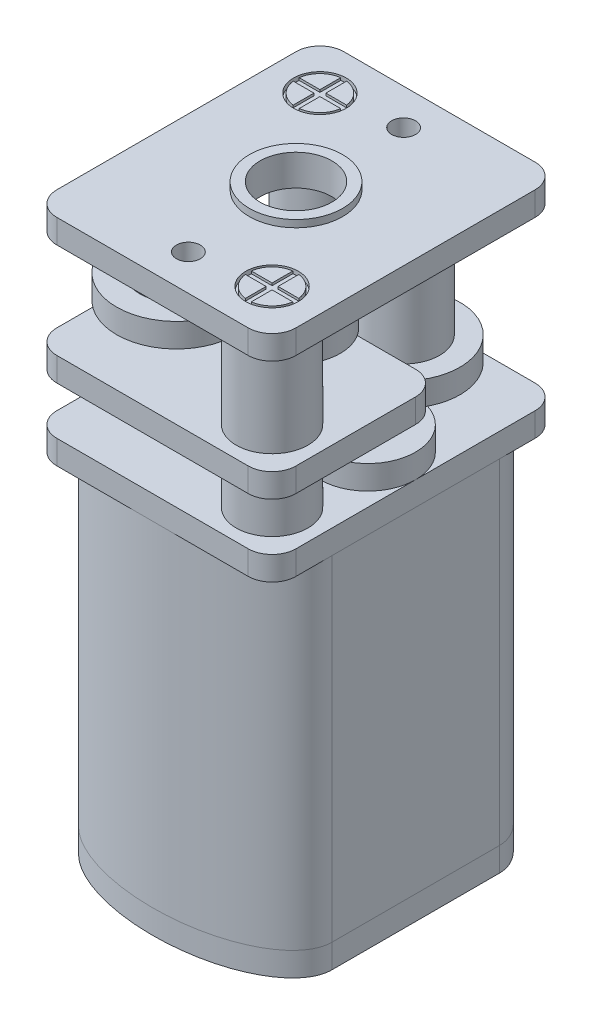
from build123d import *

# Parameters (mm, degrees)
SALIENTE_EXTRUIR1_DEPTH       = 1
CROQUIS2_R                    = 2.5
SALIENTE_EXTRUIR2_DEPTH       = 1
CROQUIS3_R                    = 1
CORTAR_EXTRUIR1_DEPTH         = 0.5
CROQUIS4_W                    = 1.5
CROQUIS4_H                    = 0.3
SALIENTE_EXTRUIR3_DEPTH       = 1.5
CROQUIS5_R                    = 0.5
CORTAR_EXTRUIR2_DEPTH         = 0.3
CROQUIS6_R                    = 0.5
CORTAR_EXTRUIR3_DEPTH         = 0.3
SALIENTE_EXTRUIR4_DEPTH       = 14
CROQUIS8_W                    = 10
CROQUIS8_H                    = 12
SALIENTE_EXTRUIR5_DEPTH       = 1
CROQUIS23_R                   = 1
SALIENTE_EXTRUIR13_DEPTH      = 1
CROQUIS25_R                   = 2
SALIENTE_EXTRUIR18_DEPTH      = 1
CROQUIS26_R                   = 1
SALIENTE_EXTRUIR19_DEPTH      = 1
CROQUIS27_R                   = 2.354101966
SALIENTE_EXTRUIR21_DEPTH      = 1
CROQUIS29_R                   = 1.5
SALIENTE_EXTRUIR22_DEPTH      = 3
REDONDEO1_R                   = 1
REDONDEO2_R                   = 1
REDONDEO3_R                   = 1
REDONDEO4_R                   = 1
CROQUIS9_R                    = 1.5
SALIENTE_EXTRUIR6_DEPTH       = 2
CROQUIS10_W                   = 10
CROQUIS10_H                   = 12
SALIENTE_EXTRUIR7_DEPTH       = 1
CROQUIS11_R                   = 1.5
SALIENTE_EXTRUIR8_DEPTH       = 4
CROQUIS12_W                   = 5
CROQUIS12_H                   = 5
CORTAR_EXTRUIR4_DEPTH         = 1
CROQUIS30_R                   = 1.854101966
SALIENTE_EXTRUIR24_DEPTH      = 1
CROQUIS31_R                   = 1
SALIENTE_EXTRUIR26_DEPTH      = 1
CROQUIS32_R                   = 2.5
SALIENTE_EXTRUIR27_DEPTH      = 1
CROQUIS33_R                   = 1.535533906
SALIENTE_EXTRUIR28_DEPTH      = 2
CROQUIS34_R                   = 0.2
SALIENTE_EXTRUIR29_DEPTH      = 2
SALIENTE_EXTRUIR29_DEPTH_BACK = 5
CROQUIS35_R                   = 0.2
SALIENTE_EXTRUIR30_DEPTH      = 4
CROQUIS36_R                   = 0.2
SALIENTE_EXTRUIR31_DEPTH      = 2
REDONDEO5_R                   = 1
REDONDEO6_R                   = 1
REDONDEO7_R                   = 1
REDONDEO8_R                   = 1
REDONDEO9_R                   = 1
CROQUIS13_W                   = 10
CROQUIS13_H                   = 12
SALIENTE_EXTRUIR9_DEPTH       = 1
CROQUIS14_R                   = 1.95
CROQUIS14_R_2                 = 1.5
SALIENTE_EXTRUIR10_DEPTH      = 0.3
CROQUIS15_R                   = 0.5
CORTAR_EXTRUIR5_DEPTH         = 1
CROQUIS16_R                   = 1.1
CORTAR_EXTRUIR6_DEPTH         = 0.2
CROQUIS17_R                   = 1
SALIENTE_EXTRUIR11_DEPTH      = 0.2
CROQUIS18_R                   = 1
SALIENTE_EXTRUIR12_DEPTH      = 0.2
CORTAR_EXTRUIR7_DEPTH         = 0.1
CORTAR_EXTRUIR8_DEPTH         = 0.1
REDONDEO10_R                  = 1
REDONDEO11_R                  = 1
REDONDEO12_R                  = 1
REDONDEO13_R                  = 1
REDONDEO14_R                  = 1
CROQUIS22_R                   = 1.5
CORTAR_EXTRUIR9_DEPTH         = 1


with BuildPart() as part:
    # Croquis1 → Saliente-Extruir1 (new body)
    with BuildSketch(Plane(origin=(0, 0, 0), x_dir=(1, 0, 0), z_dir=(0, 1, 0))):
        with BuildLine():
            Line((5, 3.5), (5, -3.5))
            add(Edge.make_bspline(
                [(-5, -3.5), (-5, -6), (0, -6), (5, -6), (5, -3.5)],
                knots=[3.141592654, 3.141592654, 3.141592654, 4.71238898, 4.71238898, 6.283185307, 6.283185307, 6.283185307], degree=2, weights=[1, 0.707106781, 1, 0.707106781, 1]))
            Line((-5, -3.5), (-5, 3.5))
            add(Edge.make_bspline(
                [(5, 3.5), (5, 6), (0, 6), (-5, 6), (-5, 3.5)],
                knots=[3.141592654, 3.141592654, 3.141592654, 4.71238898, 4.71238898, 6.283185307, 6.283185307, 6.283185307], degree=2, weights=[1, 0.707106781, 1, 0.707106781, 1]))
        make_face()
    extrude(amount=SALIENTE_EXTRUIR1_DEPTH)

    # Croquis2 → Saliente-Extruir2 (add)
    with BuildSketch(Plane.XZ):
        Circle(CROQUIS2_R)
    extrude(amount=SALIENTE_EXTRUIR2_DEPTH)

    # Croquis3 → Cortar-Extruir1 (cut)
    with BuildSketch(Plane.XZ.offset(1)):
        Circle(CROQUIS3_R)
    extrude(amount=-CORTAR_EXTRUIR1_DEPTH, mode=Mode.SUBTRACT)

    # Croquis4 → Saliente-Extruir3 (add)
    with BuildSketch(Plane.XZ):
        with Locations((0, 3.65)):
            Rectangle(CROQUIS4_W, CROQUIS4_H)
        with Locations((0, -3.65)):
            Rectangle(CROQUIS4_W, CROQUIS4_H)
    extrude(amount=SALIENTE_EXTRUIR3_DEPTH)

    # Croquis5 → Cortar-Extruir2 (cut)
    with BuildSketch(Plane(origin=(0, 0, -3.8), x_dir=(-1, 0, 0), z_dir=(0, 0, -1))):
        with Locations((0, -0.75)):
            Circle(CROQUIS5_R)
    extrude(amount=-CORTAR_EXTRUIR2_DEPTH, mode=Mode.SUBTRACT)

    # Croquis6 → Cortar-Extruir3 (cut)
    with BuildSketch(Plane.XY.offset(3.8)):
        with Locations((0, -0.75)):
            Circle(CROQUIS6_R)
    extrude(amount=-CORTAR_EXTRUIR3_DEPTH, mode=Mode.SUBTRACT)


with BuildPart() as body_2:
    # Croquis7 → Saliente-Extruir4 (new body)
    with BuildSketch(Plane(origin=(0, 1, 0), x_dir=(1, 0, 0), z_dir=(0, 1, 0))):
        with BuildLine():
            Line((-5, 3.5), (-5, -3.5))
            add(Edge.make_bspline(
                [(-5, -3.5), (-5, -6), (0, -6), (5, -6), (5, -3.5)],
                knots=[0, 0, 0, 1.570796327, 1.570796327, 3.141592654, 3.141592654, 3.141592654], degree=2, weights=[1, 0.707106781, 1, 0.707106781, 1]))
            Line((5, -3.5), (5, 3.5))
            add(Edge.make_bspline(
                [(5, 3.5), (5, 6), (0, 6), (-5, 6), (-5, 3.5)],
                knots=[3.141592654, 3.141592654, 3.141592654, 4.71238898, 4.71238898, 6.283185307, 6.283185307, 6.283185307], degree=2, weights=[1, 0.707106781, 1, 0.707106781, 1]))
        make_face()
    extrude(amount=SALIENTE_EXTRUIR4_DEPTH)


with BuildPart() as body_3:
    # Croquis8 → Saliente-Extruir5 (new body)
    with BuildSketch(Plane(origin=(0, 15, 0), x_dir=(1, 0, 0), z_dir=(0, 1, 0))):
        Rectangle(CROQUIS8_W, CROQUIS8_H)
    extrude(amount=SALIENTE_EXTRUIR5_DEPTH)

    # Redondeo1
    redondeo1_edges = [body_3.edges().sort_by_distance(p)[0] for p in [
        (-5, 15.5, -6),
    ]]
    fillet(redondeo1_edges, radius=REDONDEO1_R)

    # Redondeo2
    redondeo2_edges = [body_3.edges().sort_by_distance(p)[0] for p in [
        (5, 15.5, -6),
    ]]
    fillet(redondeo2_edges, radius=REDONDEO2_R)

    # Redondeo3
    redondeo3_edges = [body_3.edges().sort_by_distance(p)[0] for p in [
        (5, 15.5, 6),
    ]]
    fillet(redondeo3_edges, radius=REDONDEO3_R)

    # Redondeo4
    redondeo4_edges = [body_3.edges().sort_by_distance(p)[0] for p in [
        (-5, 15.5, 6),
    ]]
    fillet(redondeo4_edges, radius=REDONDEO4_R)

    # Croquis9 → Saliente-Extruir6 (add)
    with BuildSketch(Plane(origin=(0, 16, 0), x_dir=(1, 0, 0), z_dir=(0, 1, 0))):
        with Locations((-3, 4)):
            Circle(CROQUIS9_R)
        with Locations((3, -4)):
            Circle(CROQUIS9_R)
    extrude(amount=SALIENTE_EXTRUIR6_DEPTH)

    # Croquis10 → Saliente-Extruir7 (add)
    with BuildSketch(Plane(origin=(0, 18, 0), x_dir=(1, 0, 0), z_dir=(0, 1, 0))):
        Rectangle(CROQUIS10_W, CROQUIS10_H)
    extrude(amount=SALIENTE_EXTRUIR7_DEPTH)

    # Croquis11 → Saliente-Extruir8 (add)
    with BuildSketch(Plane(origin=(0, 19, 0), x_dir=(1, 0, 0), z_dir=(0, 1, 0))):
        with Locations((3, -4)):
            Circle(CROQUIS11_R)
        with Locations((-3, 4)):
            Circle(CROQUIS11_R)
    extrude(amount=SALIENTE_EXTRUIR8_DEPTH)

    # Croquis12 → Cortar-Extruir4 (cut)
    with BuildSketch(Plane(origin=(0, 19, 0), x_dir=(1, 0, 0), z_dir=(0, 1, 0))):
        with Locations((2.5, 3.5)):
            Rectangle(CROQUIS12_W, CROQUIS12_H)
    extrude(amount=-CORTAR_EXTRUIR4_DEPTH, mode=Mode.SUBTRACT)

    # Redondeo5
    redondeo5_edges = [body_3.edges().sort_by_distance(p)[0] for p in [
        (5, 18.5, -1),
    ]]
    fillet(redondeo5_edges, radius=REDONDEO5_R)

    # Redondeo6
    redondeo6_edges = [body_3.edges().sort_by_distance(p)[0] for p in [
        (0, 18.5, -6),
    ]]
    fillet(redondeo6_edges, radius=REDONDEO6_R)

    # Redondeo7
    redondeo7_edges = [body_3.edges().sort_by_distance(p)[0] for p in [
        (-5, 18.5, -6),
    ]]
    fillet(redondeo7_edges, radius=REDONDEO7_R)

    # Redondeo8
    redondeo8_edges = [body_3.edges().sort_by_distance(p)[0] for p in [
        (-5, 18.5, 6),
    ]]
    fillet(redondeo8_edges, radius=REDONDEO8_R)

    # Redondeo9
    redondeo9_edges = [body_3.edges().sort_by_distance(p)[0] for p in [
        (5, 18.5, 6),
    ]]
    fillet(redondeo9_edges, radius=REDONDEO9_R)

    # Croquis13 → Saliente-Extruir9 (add)
    with BuildSketch(Plane(origin=(0, 23, 0), x_dir=(1, 0, 0), z_dir=(0, 1, 0))):
        Rectangle(CROQUIS13_W, CROQUIS13_H)
    extrude(amount=SALIENTE_EXTRUIR9_DEPTH)

    # Croquis14 → Saliente-Extruir10 (add)
    with BuildSketch(Plane(origin=(0, 24, 0), x_dir=(1, 0, 0), z_dir=(0, 1, 0))):
        Circle(CROQUIS14_R)
        Circle(CROQUIS14_R_2, mode=Mode.SUBTRACT)
    extrude(amount=SALIENTE_EXTRUIR10_DEPTH)

    # Croquis15 → Cortar-Extruir5 (cut)
    with BuildSketch(Plane(origin=(0, 24, 0), x_dir=(1, 0, 0), z_dir=(0, 1, 0))):
        with Locations((0, 4.5)):
            Circle(CROQUIS15_R)
        with Locations((0, -4.5)):
            Circle(CROQUIS15_R)
    extrude(amount=-CORTAR_EXTRUIR5_DEPTH, mode=Mode.SUBTRACT)

    # Croquis16 → Cortar-Extruir6 (cut)
    with BuildSketch(Plane(origin=(0, 24, 0), x_dir=(1, 0, 0), z_dir=(0, 1, 0))):
        with Locations((3, -4)):
            Circle(CROQUIS16_R)
        with Locations((-3, 4)):
            Circle(CROQUIS16_R)
    extrude(amount=-CORTAR_EXTRUIR6_DEPTH, mode=Mode.SUBTRACT)

    # Redondeo10
    redondeo10_edges = [body_3.edges().sort_by_distance(p)[0] for p in [
        (-5, 23.5, 6),
    ]]
    fillet(redondeo10_edges, radius=REDONDEO10_R)

    # Redondeo11
    redondeo11_edges = [body_3.edges().sort_by_distance(p)[0] for p in [
        (5, 23.5, 6),
    ]]
    fillet(redondeo11_edges, radius=REDONDEO11_R)

    # Redondeo12
    redondeo12_edges = [body_3.edges().sort_by_distance(p)[0] for p in [
        (5, 23.5, -6),
    ]]
    fillet(redondeo12_edges, radius=REDONDEO12_R)

    # Redondeo13
    redondeo13_edges = [body_3.edges().sort_by_distance(p)[0] for p in [
        (-5, 23.5, -6),
    ]]
    fillet(redondeo13_edges, radius=REDONDEO13_R)

    # Redondeo14
    redondeo14_edges = [body_3.edges().sort_by_distance(p)[0] for p in [
        (0, 18.5, -1),
    ]]
    fillet(redondeo14_edges, radius=REDONDEO14_R)

    # Croquis22 → Cortar-Extruir9 (cut)
    with BuildSketch(Plane(origin=(0, 24, 0), x_dir=(1, 0, 0), z_dir=(0, 1, 0))):
        Circle(CROQUIS22_R)
    extrude(amount=-CORTAR_EXTRUIR9_DEPTH, mode=Mode.SUBTRACT)


with BuildPart() as body_4:
    # Croquis23 → Saliente-Extruir13 (new body)
    with BuildSketch(Plane(origin=(0, 16, 0), x_dir=(1, 0, 0), z_dir=(0, 1, 0))):
        Circle(CROQUIS23_R)
    extrude(amount=SALIENTE_EXTRUIR13_DEPTH)


with BuildPart() as body_5:
    # Croquis25 → Saliente-Extruir18 (new body)
    with BuildSketch(Plane(origin=(0, 16, 0), x_dir=(1, 0, 0), z_dir=(0, 1, 0))):
        with Locations((3, 0)):
            Circle(CROQUIS25_R)
    extrude(amount=SALIENTE_EXTRUIR18_DEPTH)

    # Croquis26 → Saliente-Extruir19 (add)
    with BuildSketch(Plane(origin=(0, 17, 0), x_dir=(1, 0, 0), z_dir=(0, 1, 0))):
        with Locations((3, 0)):
            Circle(CROQUIS26_R)
    extrude(amount=SALIENTE_EXTRUIR19_DEPTH)


with BuildPart() as body_6:
    # Croquis27 → Saliente-Extruir21 (new body)
    with BuildSketch(Plane(origin=(0, 17, 0), x_dir=(1, 0, 0), z_dir=(0, 1, 0))):
        with Locations((1.5, 3)):
            Circle(CROQUIS27_R)
    extrude(amount=SALIENTE_EXTRUIR21_DEPTH)

    # Croquis29 → Saliente-Extruir22 (add)
    with BuildSketch(Plane(origin=(0, 18, 0), x_dir=(1, 0, 0), z_dir=(0, 1, 0))):
        with Locations((1.5, 3)):
            Circle(CROQUIS29_R)
    extrude(amount=SALIENTE_EXTRUIR22_DEPTH)


with BuildPart() as body_7:
    # Croquis30 → Saliente-Extruir24 (new body)
    with BuildSketch(Plane(origin=(0, 19, 0), x_dir=(1, 0, 0), z_dir=(0, 1, 0))):
        Circle(CROQUIS30_R)
    extrude(amount=SALIENTE_EXTRUIR24_DEPTH)


with BuildPart() as body_8:
    # Croquis31 → Saliente-Extruir26 (new body)
    with BuildSketch(Plane(origin=(0, 20, 0), x_dir=(1, 0, 0), z_dir=(0, 1, 0))):
        Circle(CROQUIS31_R)
    extrude(amount=SALIENTE_EXTRUIR26_DEPTH)


with BuildPart() as body_9:
    # Croquis32 → Saliente-Extruir27 (new body)
    with BuildSketch(Plane(origin=(0, 20, 0), x_dir=(1, 0, 0), z_dir=(0, 1, 0))):
        with Locations((-2.5, -2.5)):
            Circle(CROQUIS32_R)
    extrude(amount=SALIENTE_EXTRUIR27_DEPTH)


with BuildPart() as body_10:
    # Croquis33 → Saliente-Extruir28 (new body)
    with BuildSketch(Plane(origin=(0, 21, 0), x_dir=(1, 0, 0), z_dir=(0, 1, 0))):
        with Locations((-2.5, -2.5)):
            Circle(CROQUIS33_R)
    extrude(amount=SALIENTE_EXTRUIR28_DEPTH)


with BuildPart() as body_11:
    # Croquis34 → Saliente-Extruir29 (new body, two sides)
    with BuildSketch(Plane(origin=(0, 21, 0), x_dir=(1, 0, 0), z_dir=(0, 1, 0))) as saliente_extruir29_sk:
        with Locations((1.5, 3)):
            Circle(CROQUIS34_R)
    extrude(amount=SALIENTE_EXTRUIR29_DEPTH)
    extrude(saliente_extruir29_sk.sketch, amount=-SALIENTE_EXTRUIR29_DEPTH_BACK)


with BuildPart() as body_12:
    # Croquis35 → Saliente-Extruir30 (new body)
    with BuildSketch(Plane(origin=(0, 23, 0), x_dir=(1, 0, 0), z_dir=(0, 1, 0))):
        with Locations((-2.5, -2.5)):
            Circle(CROQUIS35_R)
    extrude(amount=-SALIENTE_EXTRUIR30_DEPTH)


with BuildPart() as body_13:
    # Croquis36 → Saliente-Extruir31 (new body)
    with BuildSketch(Plane(origin=(0, 21, 0), x_dir=(1, 0, 0), z_dir=(0, 1, 0))):
        Circle(CROQUIS36_R)
    extrude(amount=SALIENTE_EXTRUIR31_DEPTH)


with BuildPart() as body_14:
    # Croquis17 → Saliente-Extruir11 (new body)
    with BuildSketch(Plane(origin=(0, 23.8, 0), x_dir=(1, 0, 0), z_dir=(0, 1, 0))):
        with Locations((-3, 4)):
            Circle(CROQUIS17_R)
    extrude(amount=SALIENTE_EXTRUIR11_DEPTH)

    # Croquis19 → Cortar-Extruir7 (cut)
    with BuildSketch(Plane(origin=(0, 24, 0), x_dir=(1, 0, 0), z_dir=(0, 1, 0))):
        with BuildLine():
            Line((-3.125, 4.125), (-3.125, 4.992156742))
            ThreePointArc((-3.125, 4.992156742), (-3, 5), (-2.875, 4.992156742))
            Line((-2.875, 4.992156742), (-2.875, 4.125))
            Line((-2.875, 4.125), (-2.007843258, 4.125))
            ThreePointArc((-2.007843258, 4.125), (-2, 4), (-2.007843258, 3.875))
            Line((-2.007843258, 3.875), (-2.875, 3.875))
            Line((-2.875, 3.875), (-2.875, 3.007843258))
            ThreePointArc((-2.875, 3.007843258), (-3, 3), (-3.125, 3.007843258))
            Line((-3.125, 3.007843258), (-3.125, 3.875))
            Line((-3.125, 3.875), (-3.992156742, 3.875))
            ThreePointArc((-3.992156742, 3.875), (-4, 4), (-3.992156742, 4.125))
            Line((-3.992156742, 4.125), (-3.125, 4.125))
        make_face()
    extrude(amount=-CORTAR_EXTRUIR7_DEPTH, mode=Mode.SUBTRACT)


with BuildPart() as body_15:
    # Croquis18 → Saliente-Extruir12 (new body)
    with BuildSketch(Plane(origin=(0, 23.8, 0), x_dir=(1, 0, 0), z_dir=(0, 1, 0))):
        with Locations((3, -4)):
            Circle(CROQUIS18_R)
    extrude(amount=SALIENTE_EXTRUIR12_DEPTH)

    # Croquis21 → Cortar-Extruir8 (cut)
    with BuildSketch(Plane(origin=(0, 24, 0), x_dir=(1, 0, 0), z_dir=(0, 1, 0))):
        with BuildLine():
            Line((2.875, -3.875), (2.875, -3.007843258))
            ThreePointArc((2.875, -3.007843258), (3, -3), (3.125, -3.007843258))
            Line((3.125, -3.007843258), (3.125, -3.875))
            Line((3.125, -3.875), (3.992156742, -3.875))
            ThreePointArc((3.992156742, -3.875), (4, -4), (3.992156742, -4.125))
            Line((3.992156742, -4.125), (3.125, -4.125))
            Line((3.125, -4.125), (3.125, -4.992156742))
            ThreePointArc((3.125, -4.992156742), (3, -5), (2.875, -4.992156742))
            Line((2.875, -4.992156742), (2.875, -4.125))
            Line((2.875, -4.125), (2.007843258, -4.125))
            ThreePointArc((2.007843258, -4.125), (2, -4), (2.007843258, -3.875))
            Line((2.007843258, -3.875), (2.875, -3.875))
        make_face()
    extrude(amount=-CORTAR_EXTRUIR8_DEPTH, mode=Mode.SUBTRACT)


solid = Compound([part.part, body_2.part, body_3.part, body_4.part, body_5.part, body_6.part, body_7.part, body_8.part, body_9.part, body_10.part, body_11.part, body_12.part, body_13.part, body_14.part, body_15.part])
